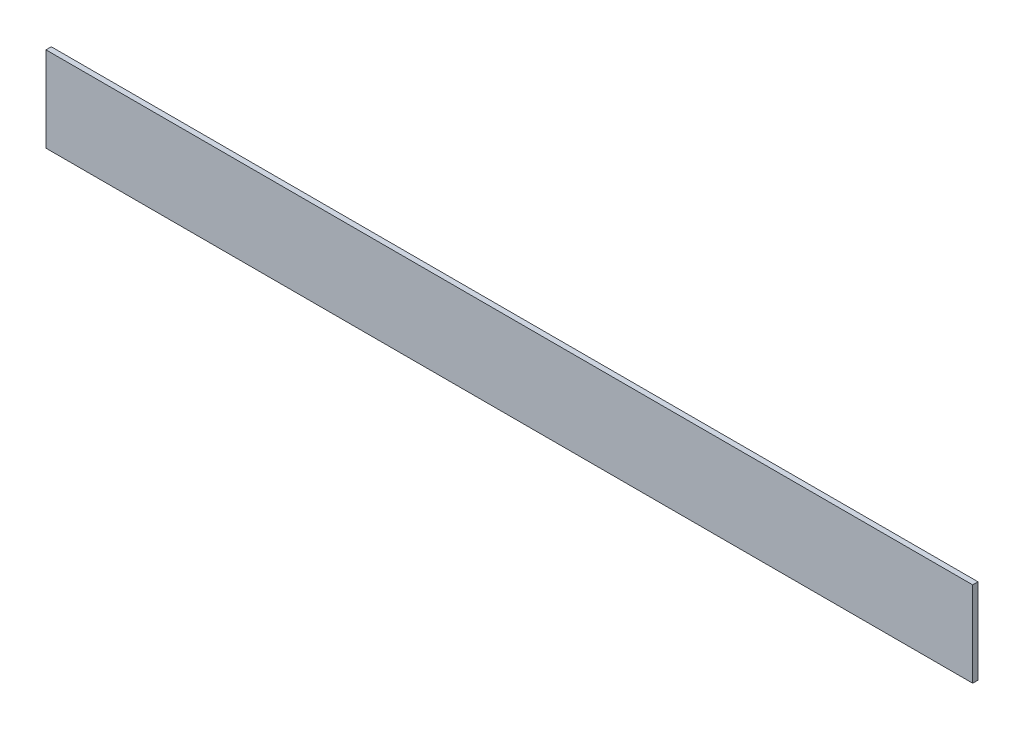
from build123d import *

# Parameters (mm, degrees)
SKETCH1_W           = 552.45
SKETCH1_H           = 50.8
BOSS_EXTRUDE1_DEPTH = 3.175


with BuildPart() as part:
    # Sketch1 → Boss-Extrude1 (new body)
    with BuildSketch(Plane.XY):
        with Locations((276.225, 25.4)):
            Rectangle(SKETCH1_W, SKETCH1_H)
    extrude(amount=BOSS_EXTRUDE1_DEPTH)


solid = part.part
